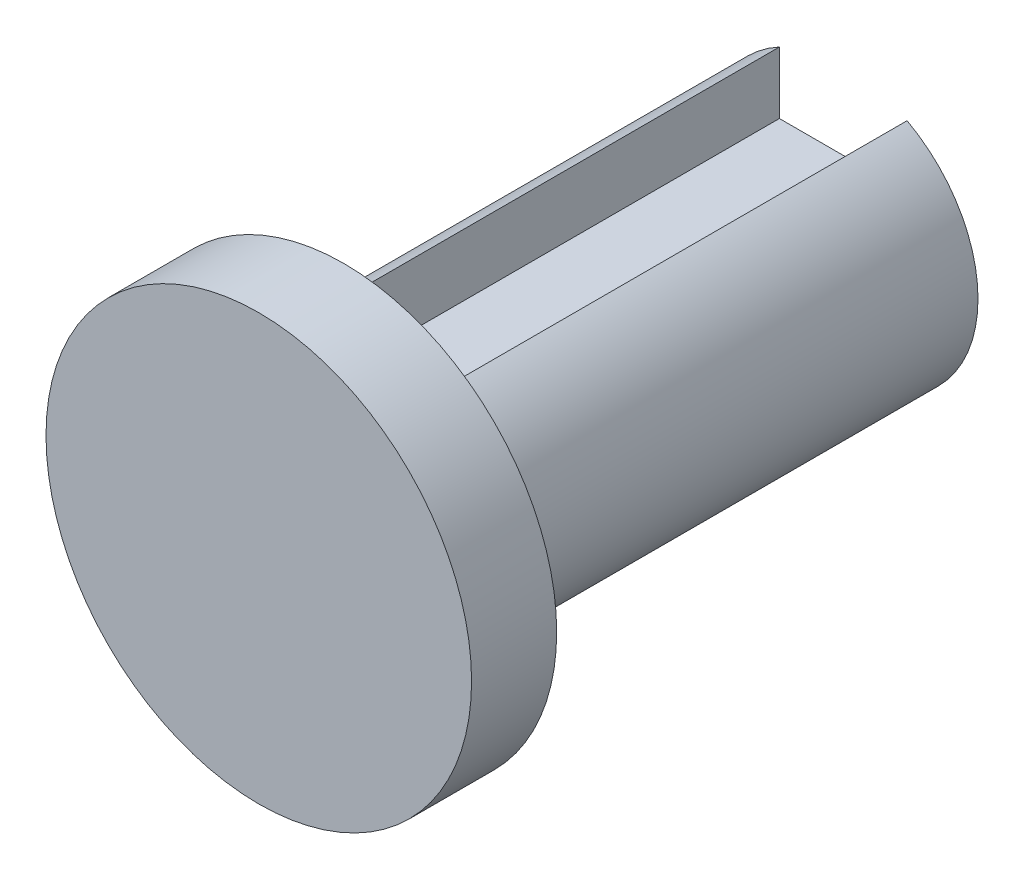
from build123d import *

# Parameters (mm, degrees)
SKETCH1_R           = 15
BOSS_EXTRUDE1_DEPTH = 6
BOSS_EXTRUDE2_DEPTH = 35.2


with BuildPart() as part:
    # Sketch1 → Boss-Extrude1 (new body)
    with BuildSketch(Plane.XY):
        Circle(SKETCH1_R)
    extrude(amount=BOSS_EXTRUDE1_DEPTH)

    # Sketch1_3 → Boss-Extrude2 (add)
    with BuildSketch(Plane.XY):
        with BuildLine():
            Line((4.5, 8.366600265), (4.5, 4))
            Line((4.5, 4), (-4.5, 4))
            Line((-4.5, 4), (-4.5, 8.366600265))
            ThreePointArc((-4.5, 8.366600265), (-4.873397172, -8.154753215), (9.5, 0))
            ThreePointArc((9.5, 0), (8.154753215, 4.873397172), (4.5, 8.366600265))
        make_face()
    extrude(amount=-BOSS_EXTRUDE2_DEPTH)


solid = part.part
